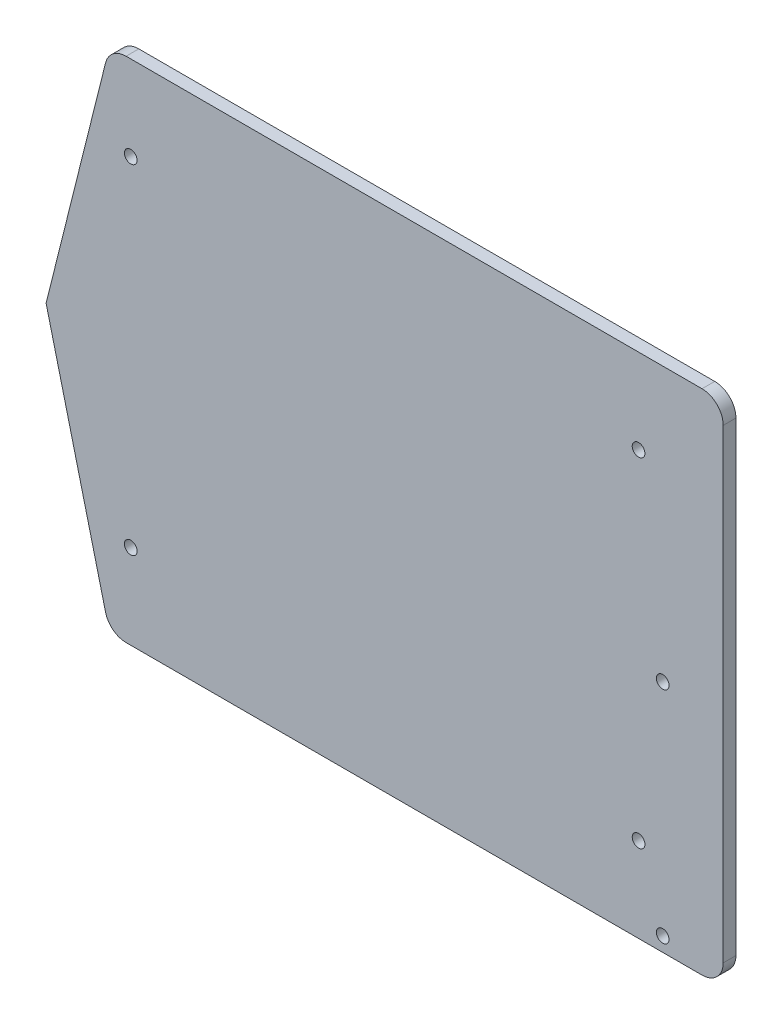
from build123d import *

# Parameters (mm, degrees)
SKETCH_1_R          = 1.5
EXTRUDE_1_DEPTH     = 3
FILLET_1_R          = 5
SKETCH_2_R          = 1.5
CUT_EXTRUDE_1_DEPTH = 10


with BuildPart() as part:
    # 草圖1 → 填料-伸長1 (new body)
    with BuildSketch(Plane.XY):
        Polygon((15, 120), (160, 120), (160, 0), (15, 0), (0, 60), align=None)
        with Locations((20, 20)):
            Circle(SKETCH_1_R, mode=Mode.SUBTRACT)
        with Locations((20, 100)):
            Circle(SKETCH_1_R, mode=Mode.SUBTRACT)
        with Locations((140, 20)):
            Circle(SKETCH_1_R, mode=Mode.SUBTRACT)
        with Locations((140, 100)):
            Circle(SKETCH_1_R, mode=Mode.SUBTRACT)
    extrude(amount=EXTRUDE_1_DEPTH)

    # 圓角1
    fillet_1_edges = [part.edges().sort_by_distance(p)[0] for p in [
        (160, 0, 1.5),
        (15, 0, 1.5),
        (15, 120, 1.5),
        (160, 120, 1.5),
    ]]
    fillet(fillet_1_edges, radius=FILLET_1_R)

    # 草圖2 → 除料-伸長1 (cut)
    with BuildSketch(Plane.XY.offset(3)):
        with Locations((145.7, 3.38)):
            Circle(SKETCH_2_R)
        with Locations((145.7, 55.38)):
            Circle(SKETCH_2_R)
    extrude(amount=-CUT_EXTRUDE_1_DEPTH, mode=Mode.SUBTRACT)


solid = part.part
